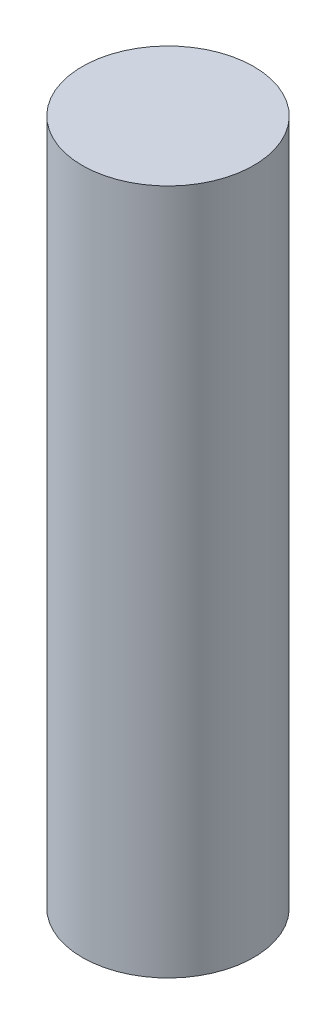
from build123d import *

# Parameters (mm, degrees)
SKETCH1_R           = 0.25
BOSS_EXTRUDE1_DEPTH = 2


with BuildPart() as part:
    # Sketch1 → Boss-Extrude1 (new body)
    with BuildSketch(Plane(origin=(0, 0, 0), x_dir=(1, 0, 0), z_dir=(0, 1, 0))):
        Circle(SKETCH1_R)
    extrude(amount=BOSS_EXTRUDE1_DEPTH)


solid = part.part
